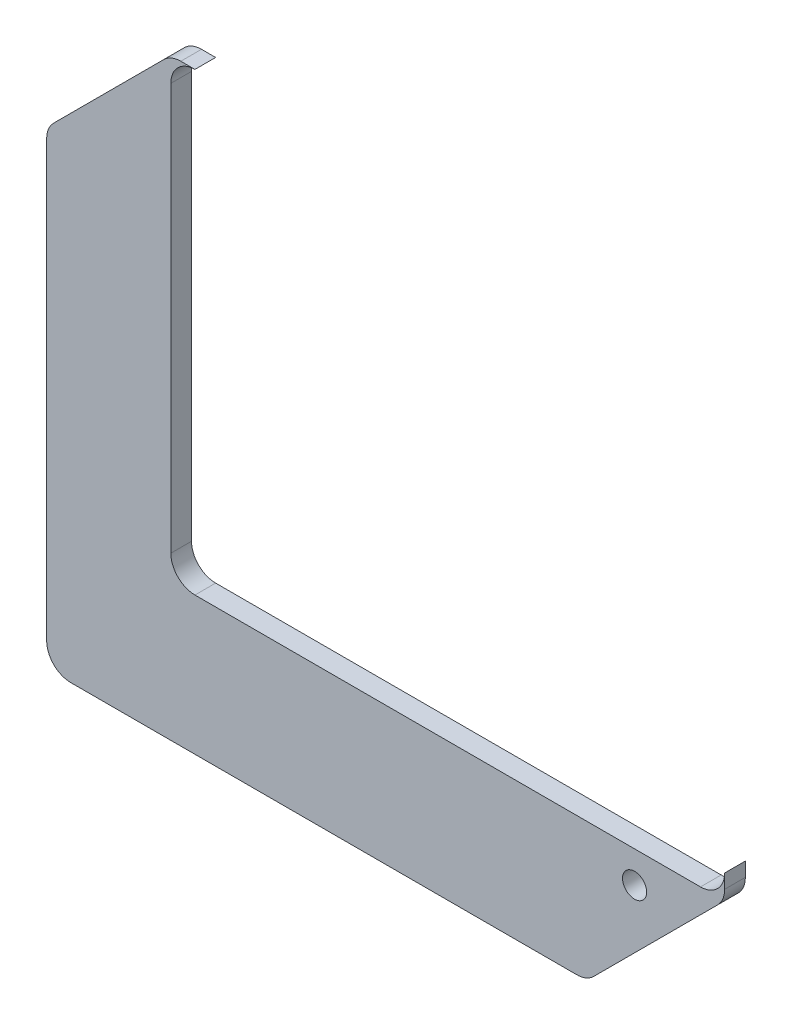
from build123d import *

# Parameters (mm, degrees)
SKETCH1_W                  = 80.3
SKETCH1_H                  = 66
BOSS_EXTRUDE1_DEPTH        = 3
FILLET1_R                  = 3.5
SKETCH2_R                  = 3.5
CUT_EXTRUDE1_DEPTH         = 4
FILLET2_R                  = 3.5
F_3_5_3_5_DIAMETER_HOLE1_D = 3.5


with BuildPart() as part:
    # Sketch1 → Boss-Extrude1 (new body)
    with BuildSketch(Plane.XY):
        Polygon((-18, -20), (60.3, -20), (80.3, 0), (0, 0), (0, 66), (-18, 48), align=None)
        with Locations((40.15, 33)):
            Rectangle(SKETCH1_W, SKETCH1_H)
    extrude(amount=BOSS_EXTRUDE1_DEPTH)

    # Fillet1
    fillet1_edges = [part.edges().sort_by_distance(p)[0] for p in [
        (60.3, -20, 1.5),
        (-18, -20, 1.5),
        (-18, 48, 1.5),
        (0, 66, 1.5),
        (80.3, 66, 1.5),
        (80.3, 0, 1.5),
    ]]
    fillet(fillet1_edges, radius=FILLET1_R)

    # Sketch2 → Cut-Extrude1 (cut, through all)
    with BuildSketch(Plane.XY.offset(3)):
        with BuildLine():
            Line((0, 62.5), (0, 0))
            Line((0, 0), (76.8, 0))
            ThreePointArc((76.8, 0), (74.325126266, 5.974873734), (80.3, 3.5))
            Line((80.3, 3.5), (80.3, 62.5))
            ThreePointArc((80.3, 62.5), (74.325126266, 60.025126266), (76.8, 66))
            Line((76.8, 66), (3.500000005, 66))
            ThreePointArc((3.500000005, 66), (5.974873736, 64.974873732), (7, 62.5))
            ThreePointArc((7, 62.5), (3.5, 59), (0, 62.5))
        make_face()
        with Locations((3.5, 62.5)):
            Circle(SKETCH2_R)
        with BuildLine():
            ThreePointArc((76.8, 66), (74.325126266, 60.025126266), (80.3, 62.5))
            ThreePointArc((80.3, 62.5), (79.274873734, 64.974873734), (76.8, 66))
        make_face()
        with Locations((76.8, 3.5)):
            Circle(SKETCH2_R)
    extrude(amount=-CUT_EXTRUDE1_DEPTH, mode=Mode.SUBTRACT)

    # Fillet2
    fillet2_edges = [part.edges().sort_by_distance(p)[0] for p in [
        (0, 0, 1.5),
    ]]
    fillet(fillet2_edges, radius=FILLET2_R)

    # Ø3.5 (3.5) Diameter Hole1 (through all)
    with Locations(Plane.XY.offset(3)):
        with Locations((67.24, -4.57)):
            Hole(F_3_5_3_5_DIAMETER_HOLE1_D / 2)


solid = part.part
